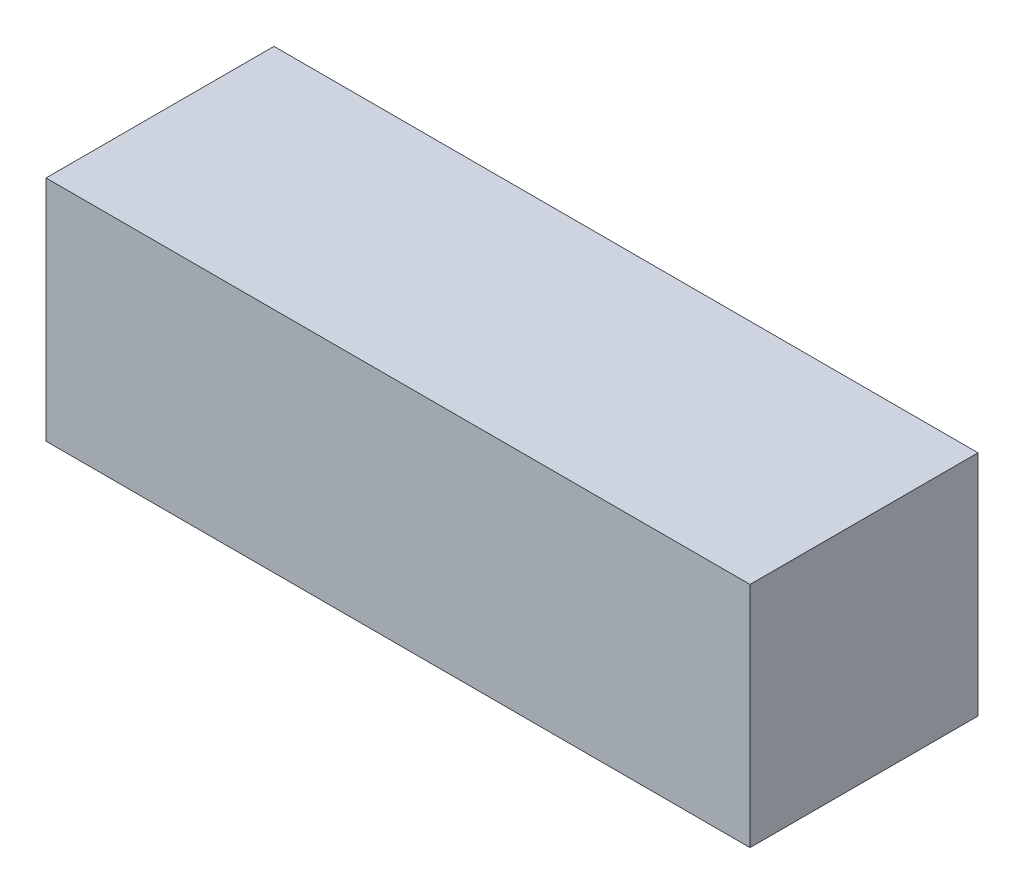
from build123d import *

# Parameters (mm, degrees)
SKETCH1_W           = 53.34
SKETCH1_H           = 17.272
BOSS_EXTRUDE1_DEPTH = 8.636


with BuildPart() as part:
    # Sketch1 → Boss-Extrude1 (new body, symmetric)
    with BuildSketch(Plane(origin=(0, 0, 0), x_dir=(1, 0, 0), z_dir=(0, 1, 0))):
        Rectangle(SKETCH1_W, SKETCH1_H)
    extrude(amount=BOSS_EXTRUDE1_DEPTH, both=True)


solid = part.part
